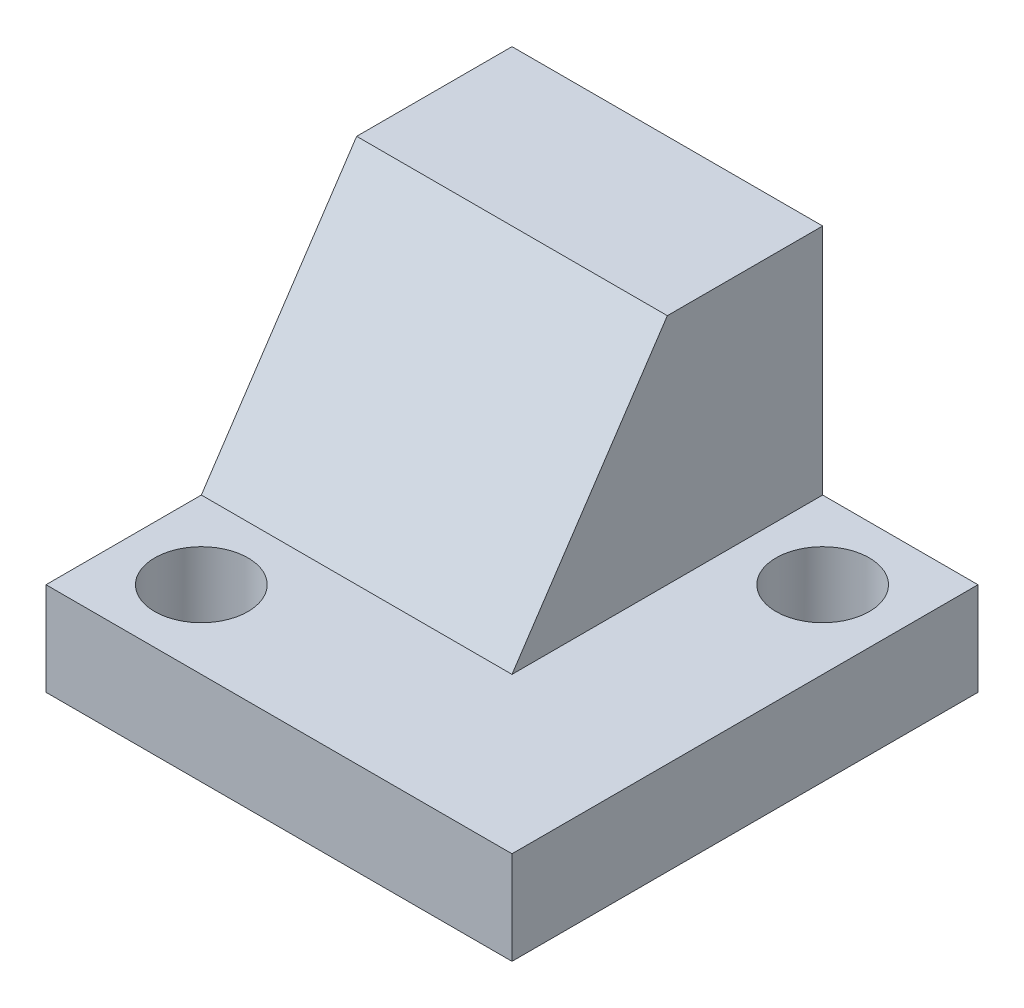
from build123d import *

# Parameters (mm, degrees)
SKETCH1_W           = 38.1
SKETCH1_H           = 38.1
BOSS_EXTRUDE1_DEPTH = 7.62
SKETCH2_W           = 25.4
SKETCH2_H           = 25.4
BOSS_EXTRUDE2_DEPTH = 19.05
CUT_EXTRUDE1_REACH  = 9.62
SKETCH3_R           = 3.81
CUT_EXTRUDE2_DEPTH  = 6.35
CUT_EXTRUDE3_REACH  = 40.1


with BuildPart() as part:
    # Sketch1 → Boss-Extrude1 (new body)
    with BuildSketch(Plane(origin=(0, 0, 0), x_dir=(1, 0, 0), z_dir=(0, 1, 0))):
        Rectangle(SKETCH1_W, SKETCH1_H)
    extrude(amount=BOSS_EXTRUDE1_DEPTH)

    # Sketch2 → Boss-Extrude2 (add)
    with BuildSketch(Plane(origin=(0, 7.62, 0), x_dir=(1, 0, 0), z_dir=(0, 1, 0))):
        with Locations((-6.35, 6.35)):
            Rectangle(SKETCH2_W, SKETCH2_H)
    extrude(amount=BOSS_EXTRUDE2_DEPTH)

    # Sketch3 → Cut-Extrude1 (cut, up to next)
    with BuildSketch(Plane(origin=(0, 7.62, 0), x_dir=(1, 0, 0), z_dir=(0, 1, 0)), mode=Mode.PRIVATE) as cut_extrude1_sk1:
        with Locations((12.7, 12.7)):
            Circle(SKETCH3_R)
    cut_extrude1_tool1 = extrude(cut_extrude1_sk1.sketch, amount=-CUT_EXTRUDE1_REACH, mode=Mode.PRIVATE) & part.part
    add(cut_extrude1_tool1.solids().sort_by_distance((12.7, 7.62, -12.7))[0], mode=Mode.SUBTRACT)
    # Sketch3 → Cut-Extrude1 (cut, up to next)
    with BuildSketch(Plane(origin=(0, 7.62, 0), x_dir=(1, 0, 0), z_dir=(0, 1, 0)), mode=Mode.PRIVATE) as cut_extrude1_sk2:
        with Locations((-12.7, -12.7)):
            Circle(SKETCH3_R)
    cut_extrude1_tool2 = extrude(cut_extrude1_sk2.sketch, amount=-CUT_EXTRUDE1_REACH, mode=Mode.PRIVATE) & part.part
    add(cut_extrude1_tool2.solids().sort_by_distance((-12.7, 7.62, 12.7))[0], mode=Mode.SUBTRACT)

    # Sketch4 → Cut-Extrude2 (cut)
    with BuildSketch(Plane.ZY.offset(19.05)):
        Polygon((-13.335, 21.59), (-10.541, 21.59), (-10.541, 10.414), (0.635, 10.414), (0.635, 7.62), (-13.335, 7.62), align=None)
    extrude(amount=-CUT_EXTRUDE2_DEPTH, mode=Mode.SUBTRACT)

    # Sketch5 → Cut-Extrude3 (cut, up to next)
    with BuildSketch(Plane.ZY.offset(19.05), mode=Mode.PRIVATE) as cut_extrude3_sk1:
        Polygon((-6.35, 26.67), (6.35, 7.62), (6.35, 26.67), align=None)
    cut_extrude3_tool1 = extrude(cut_extrude3_sk1.sketch, amount=-CUT_EXTRUDE3_REACH, mode=Mode.PRIVATE) & part.part
    add(cut_extrude3_tool1.solids().sort_by_distance((-19.05, 20.32, 2.116667))[0], mode=Mode.SUBTRACT)


solid = part.part
